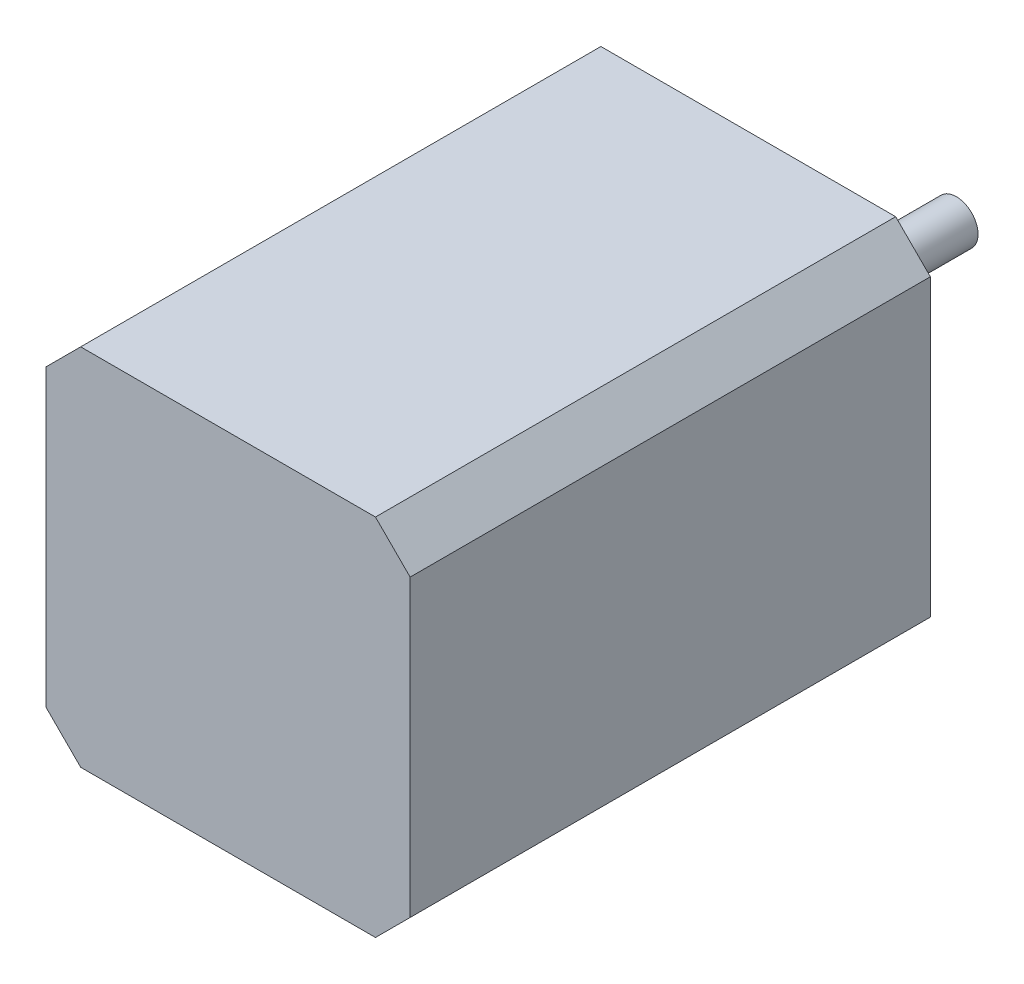
from build123d import *

# Parameters (mm, degrees)
SKETCH_1_W               = 42
SKETCH_1_H               = 42
EXTRUDE_1_DEPTH          = 60
SKETCH_8_R               = 2.5
EXTRUDE_2_DEPTH          = 24
CUT_EXTRUDE_1_DEPTH      = 85
PATTERN_CIRCULAR_1_COUNT = 4
SKETCH_12_R              = 11
EXTRUDE_3_DEPTH          = 2


with BuildPart() as part:
    # Эскиз1 → Бобышка-Вытянуть1 (new body)
    with BuildSketch(Plane.XY):
        Rectangle(SKETCH_1_W, SKETCH_1_H)
    extrude(amount=EXTRUDE_1_DEPTH)

    # Эскиз8 → Бобышка-Вытянуть2 (add)
    with BuildSketch(Plane(origin=(0, 0, 0), x_dir=(-1, 0, 0), z_dir=(0, 0, -1))):
        Circle(SKETCH_8_R)
    extrude(amount=EXTRUDE_2_DEPTH)

    # Эскиз9 → Отверстие обработанное метчиком M32 (revolve, cut)
    with BuildSketch(Plane(origin=(-15.5, -15.5, 0), x_dir=(0, 1, 0), z_dir=(1, 0, 0))):
        Polygon((0, 0), (0, 8.251075774), (1.25, 7.5), (1.25, 0), align=None)
    hole_wizard_m32 = revolve(axis=Axis((-15.5, -15.5, -6.35), (0, 0, 1)), mode=Mode.SUBTRACT)

    # Эскиз3 → Вырез-Вытянуть1 (cut, through all)
    with BuildSketch(Plane.XY.offset(60)):
        Polygon((-21, 17), (-17, 21), (-21, 21), align=None)
    cut_extrude_1 = extrude(amount=-CUT_EXTRUDE_1_DEPTH, mode=Mode.SUBTRACT)

    # Круговой массив1: Отверстие обработанное метчиком M32, Вырез-Вытянуть1 ×4 about axis
    pattern_circular_1_axis = Axis((0, 0, 0), (0, 0, 1))
    for i in range(1, PATTERN_CIRCULAR_1_COUNT):
        add(hole_wizard_m32.rotate(pattern_circular_1_axis, i * 360 / PATTERN_CIRCULAR_1_COUNT), mode=Mode.SUBTRACT)
        add(cut_extrude_1.rotate(pattern_circular_1_axis, i * 360 / PATTERN_CIRCULAR_1_COUNT), mode=Mode.SUBTRACT)

    # Эскиз12 → Бобышка-Вытянуть3 (add)
    with BuildSketch(Plane(origin=(0, 0, 0), x_dir=(-1, 0, 0), z_dir=(0, 0, -1))):
        Circle(SKETCH_12_R)
    extrude(amount=EXTRUDE_3_DEPTH)


solid = part.part
